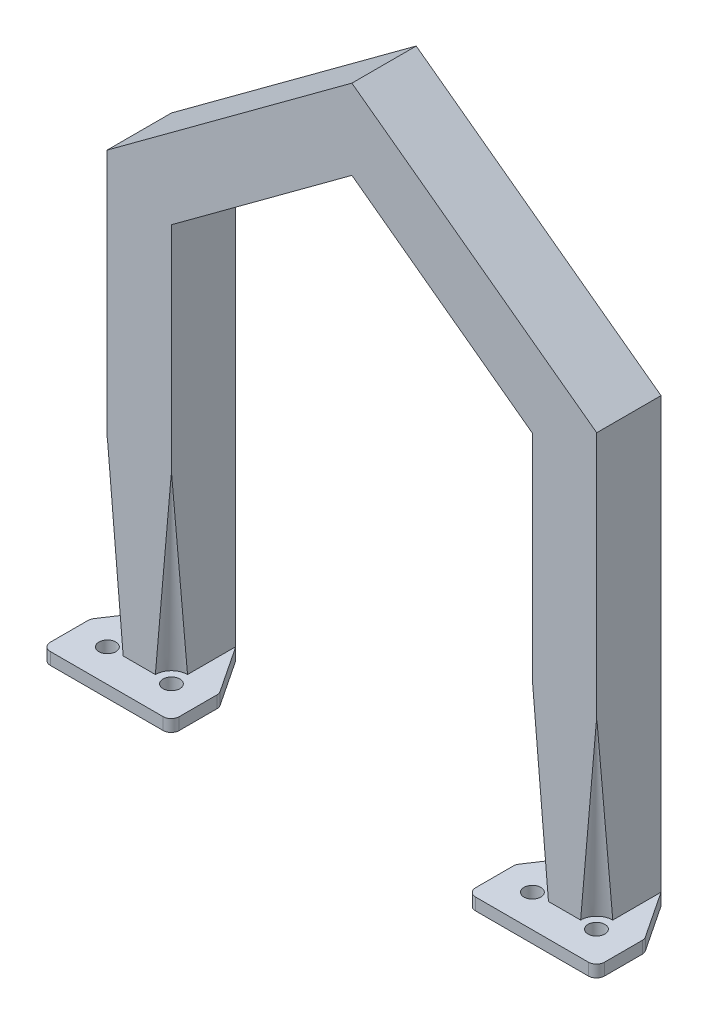
from build123d import *

# Parameters (mm, degrees)
BOSS_EXTRUDE1_DEPTH  = 8
SKETCH2_R            = 4
CUT_EXTRUDE1_DEPTH   = 45
CUT_EXTRUDE1_TAPER   = 5
SKETCH3_R            = 2.1
BOSS_EXTRUDE2_DEPTH  = 3
FILLET1_R            = 2
FILLET1_OF_MIRROR1_R = 2


with BuildPart() as part:
    # Sketch1 → Boss-Extrude1 (new body, symmetric)
    with BuildSketch(Plane.XY):
        Polygon((-60.9, 0), (-60.9, 107), (0, 151.8745296), (60.9, 107), (60.9, 0), (44.9, 0), (44.9, 98.91516619), (0, 132), (-44.9, 98.91516619), (-44.9, 0), align=None)
    extrude(amount=BOSS_EXTRUDE1_DEPTH, both=True)

    # Sketch2 → Cut-Extrude1 (cut)
    with BuildSketch(Plane.XZ):
        with Locations((-60.9, 8)):
            Circle(SKETCH2_R)
        with Locations((-44.9, 8)):
            Circle(SKETCH2_R)
    cut_extrude1 = extrude(amount=-CUT_EXTRUDE1_DEPTH, taper=CUT_EXTRUDE1_TAPER, mode=Mode.SUBTRACT)

    # Sketch3 → Boss-Extrude2 (add)
    with BuildSketch(Plane.XZ):
        Polygon((-60.9, -8), (-68.936989859, 4.1), (-68.936989859, 16.1), (-36.863010141, 16.1), (-36.863010141, 4.1), (-44.9, -8), align=None)
        with Locations((-60.836989859, 8)):
            Circle(SKETCH3_R, mode=Mode.SUBTRACT)
        with Locations((-44.9, 8)):
            Circle(SKETCH3_R, mode=Mode.SUBTRACT)
    boss_extrude2 = extrude(amount=BOSS_EXTRUDE2_DEPTH)

    # Fillet1
    fillet1_edges = [part.edges().sort_by_distance(p)[0] for p in [
        (-36.863010141, -1.5, 4.1),
        (-36.863010141, -1.5, 16.1),
        (-68.936989859, -1.5, 16.1),
        (-68.936989859, -1.5, 4.1),
    ]]
    fillet(fillet1_edges, radius=FILLET1_R)

    # Mirror1: Cut-Extrude1, Boss-Extrude2 across plane
    add(cut_extrude1.mirror(Plane(origin=(0, 0, 0), x_dir=(0, 0, 1), z_dir=(1, 0, 0))), mode=Mode.SUBTRACT)
    add(boss_extrude2.mirror(Plane(origin=(0, 0, 0), x_dir=(0, 0, 1), z_dir=(1, 0, 0))))

    # Fillet1 of Mirror1
    fillet1_of_mirror1_edges = [part.edges().sort_by_distance(p)[0] for p in [
        (36.863010141, -1.5, 4.1),
        (36.863010141, -1.5, 16.1),
        (68.936989859, -1.5, 16.1),
        (68.936989859, -1.5, 4.1),
    ]]
    fillet(fillet1_of_mirror1_edges, radius=FILLET1_OF_MIRROR1_R)


solid = part.part
